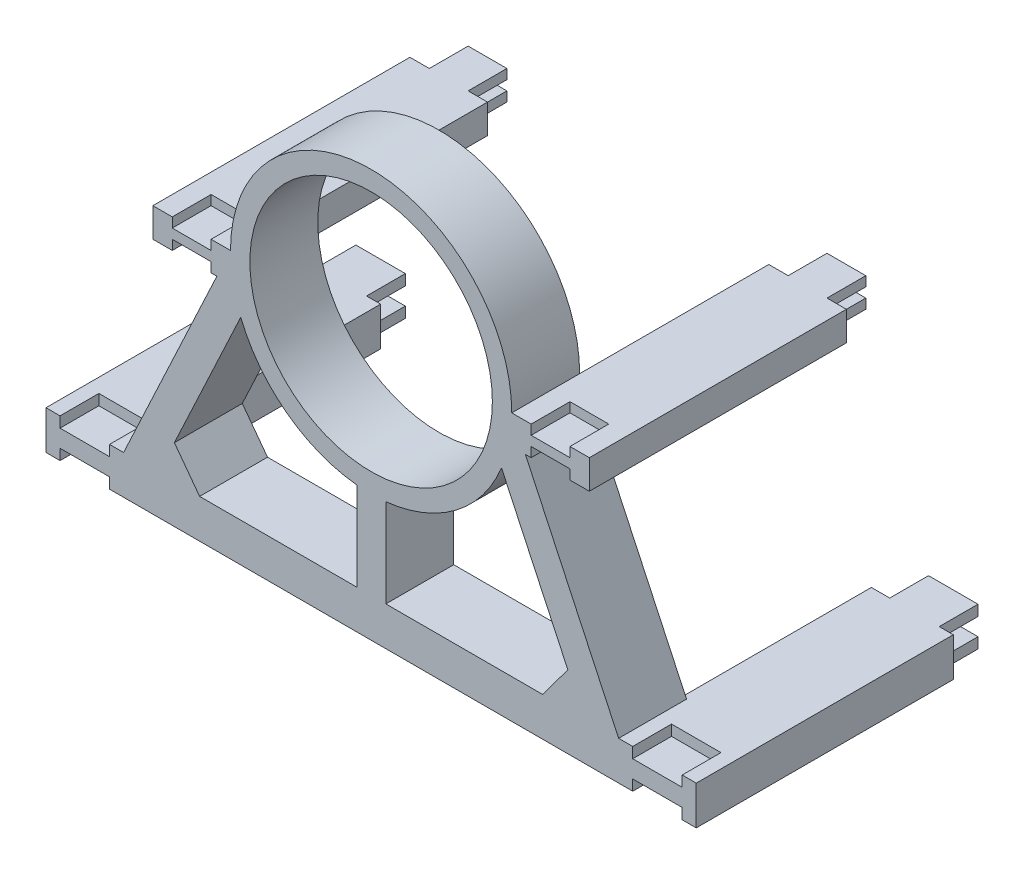
from build123d import *

# Parameters (mm, degrees)
SKETCH1_R            = 62.5
BOSS_EXTRUDE8_DEPTH  = 35
BOSS_EXTRUDE9_REACH  = 192.245
SKETCH2_W            = 15
SKETCH2_H            = 35
SKETCH10_W           = 35
SKETCH10_H           = 15
BOSS_EXTRUDE12_DEPTH = 40
SKETCH6_W            = 35
SKETCH6_H            = 15
BOSS_EXTRUDE10_DEPTH = 40
SKETCH12_W           = 42.229373335
SKETCH12_H           = 20
SKETCH12_W_2         = 40
SKETCH12_H_2         = 15
SKETCH12_W_3         = 39.995847529
BOSS_EXTRUDE13_DEPTH = 97.5
SKETCH13_W           = 20
SKETCH13_H           = 5
SKETCH13_W_2         = 25.5
SKETCH13_H_2         = 5.5
CUT_EXTRUDE1_DEPTH   = 20
SKETCH14_W           = 20
SKETCH14_H           = 5
SKETCH14_W_2         = 25.5
SKETCH14_H_2         = 5.5
BOSS_EXTRUDE14_DEPTH = 20


with BuildPart() as part:
    # Sketch1 → Boss-Extrude8 (new body)
    with BuildSketch(Plane.XY):
        with BuildLine():
            Line((127.600917431, -117.745016448), (72.5, 0))
            ThreePointArc((72.5, 0), (0, 72.5), (-72.5, 0))
            Line((-72.5, 0), (-127.600917431, -117.745016448))
            Line((-127.600917431, -117.745016448), (-167.600917431, -117.745016448))
            Line((-167.600917431, -117.745016448), (-167.600917431, -137.745016448))
            Line((-167.600917431, -137.745016448), (167.600917431, -137.745016448))
            Line((167.600917431, -137.745016448), (167.600917431, -117.745016448))
            Line((167.600917431, -117.745016448), (127.600917431, -117.745016448))
        make_face()
        with BuildLine():
            ThreePointArc((-67.21559633, -27.171926873), (0, -72.5), (67.21559633, -27.171926873))
            Line((67.21559633, -27.171926873), (101.417450928, -100.25778678))
            Line((101.417450928, -100.25778678), (88.408256881, -117.745016448))
            Line((88.408256881, -117.745016448), (-88.408256881, -117.745016448))
            Line((-88.408256881, -117.745016448), (-101.417450928, -100.25778678))
            Line((-101.417450928, -100.25778678), (-67.21559633, -27.171926873))
        make_face(mode=Mode.SUBTRACT)
        Circle(SKETCH1_R, mode=Mode.SUBTRACT)
    extrude(amount=BOSS_EXTRUDE8_DEPTH)

    # Sketch2 → Boss-Extrude9 (add, up to next)
    with BuildSketch(Plane(origin=(0, -117.745016448, 0), x_dir=(1, 0, 0), z_dir=(0, 1, 0)), mode=Mode.PRIVATE) as boss_extrude9_sk1:
        with Locations((0.093911399, -17.5)):
            Rectangle(SKETCH2_W, SKETCH2_H)
    boss_extrude9_tool1 = extrude(boss_extrude9_sk1.sketch, amount=BOSS_EXTRUDE9_REACH, mode=Mode.PRIVATE) - part.part
    add(boss_extrude9_tool1.solids().sort_by_distance((0.093911, -117.745016, 17.5))[0])

    # Sketch10 → Boss-Extrude12 (add)
    with BuildSketch(Plane(origin=(-72.5, 0, 0), x_dir=(0, 0, -1), z_dir=(1, 0, 0))):
        with Locations((-17.5, -7.5)):
            Rectangle(SKETCH10_W, SKETCH10_H)
    extrude(amount=-BOSS_EXTRUDE12_DEPTH)

    # Sketch6 → Boss-Extrude10 (add)
    with BuildSketch(Plane(origin=(72.5, 0, 0), x_dir=(0, 0, -1), z_dir=(1, 0, 0))):
        with Locations((-17.5, -7.5)):
            Rectangle(SKETCH6_W, SKETCH6_H)
    extrude(amount=BOSS_EXTRUDE10_DEPTH)

    # Sketch12 → Boss-Extrude13 (add)
    with BuildSketch(Plane(origin=(0, 0, 0), x_dir=(-1, 0, 0), z_dir=(0, 0, -1))):
        with Locations((-146.486230764, -127.745016448)):
            Rectangle(SKETCH12_W, SKETCH12_H)
        with Locations((147.600917431, -127.745016448)):
            Rectangle(SKETCH12_W_2, SKETCH12_H)
        with Locations((-92.5, -7.5)):
            Rectangle(SKETCH12_W_2, SKETCH12_H_2)
        with Locations((92.502076235, -7.5)):
            Rectangle(SKETCH12_W_3, SKETCH12_H_2)
    extrude(amount=BOSS_EXTRUDE13_DEPTH)

    # Sketch13 → Cut-Extrude1 (cut)
    with BuildSketch(Plane.XY.offset(35)):
        with Locations((-92.5, -12.5)):
            Rectangle(SKETCH13_W, SKETCH13_H)
        with Locations((-147.600917431, -134.995016448)):
            Rectangle(SKETCH13_W_2, SKETCH13_H_2)
        with Locations((-92.5, -2.5)):
            Rectangle(SKETCH13_W, SKETCH13_H)
        with Locations((92.5, -2.5)):
            Rectangle(SKETCH13_W, SKETCH13_H)
        with Locations((92.5, -12.5)):
            Rectangle(SKETCH13_W, SKETCH13_H)
        with Locations((147.600917431, -120.495016448)):
            Rectangle(SKETCH13_W_2, SKETCH13_H_2)
        with Locations((147.600917431, -134.995016448)):
            Rectangle(SKETCH13_W_2, SKETCH13_H_2)
        with Locations((-147.600917431, -120.495016448)):
            Rectangle(SKETCH13_W_2, SKETCH13_H_2)
    extrude(amount=-CUT_EXTRUDE1_DEPTH, mode=Mode.SUBTRACT)

    # Sketch14 → Boss-Extrude14 (add)
    with BuildSketch(Plane(origin=(0, 0, -97.5), x_dir=(-1, 0, 0), z_dir=(0, 0, -1))):
        with Locations((-92.5, -2.5)):
            Rectangle(SKETCH14_W, SKETCH14_H)
        with Locations((-92.5, -12.5)):
            Rectangle(SKETCH14_W, SKETCH14_H)
        with Locations((92.5, -2.5)):
            Rectangle(SKETCH14_W, SKETCH14_H)
        with Locations((92.5, -12.5)):
            Rectangle(SKETCH14_W, SKETCH14_H)
        with Locations((147.600917431, -120.495016448)):
            Rectangle(SKETCH14_W_2, SKETCH14_H_2)
        with Locations((147.600917431, -134.995016448)):
            Rectangle(SKETCH14_W_2, SKETCH14_H_2)
        with Locations((-147.600917431, -120.495016448)):
            Rectangle(SKETCH14_W_2, SKETCH14_H_2)
        with Locations((-147.600917431, -134.995016448)):
            Rectangle(SKETCH14_W_2, SKETCH14_H_2)
    extrude(amount=BOSS_EXTRUDE14_DEPTH)


solid = part.part
